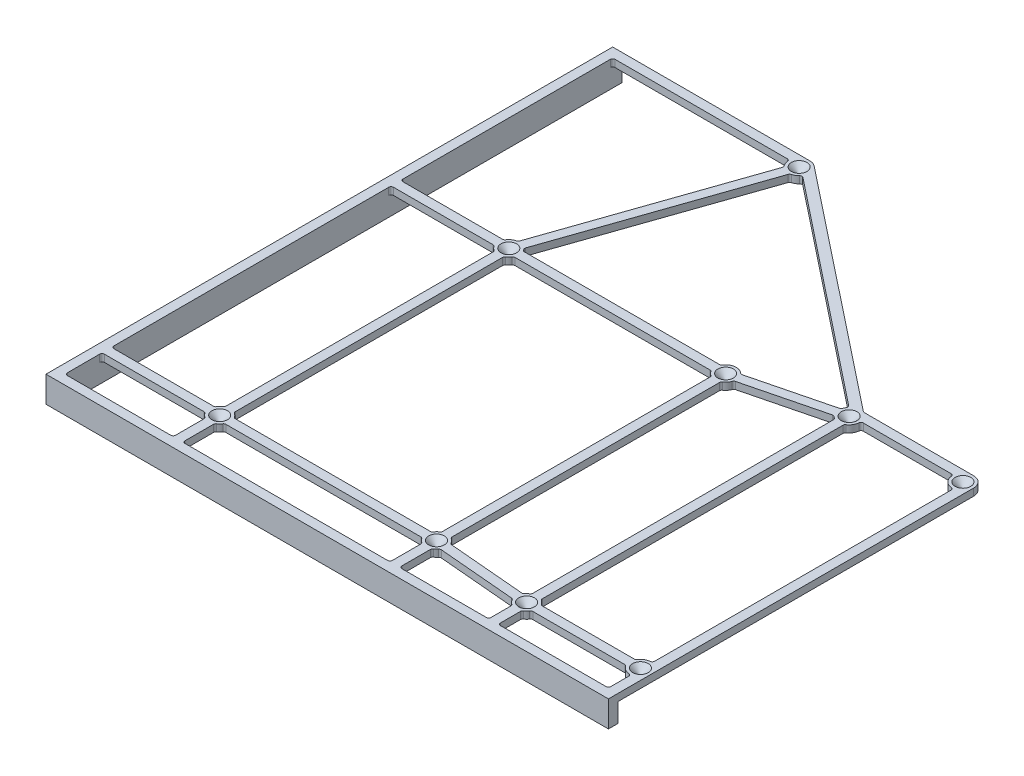
from build123d import *

# Parameters (mm, degrees)
SKETCH1_R           = 0.5
BOSS_EXTRUDE1_DEPTH = 3
BOSS_EXTRUDE2_DEPTH = 8
CHAMFER1_SIZE       = 2.8
FILLET1_R           = 1


with BuildPart() as part:
    # Sketch1 → Boss-Extrude1 (new body)
    with BuildSketch(Plane(origin=(0, 0, 0), x_dir=(1, 0, 0), z_dir=(0, 1, 0))):
        with BuildLine():
            Line((0, 234.968858619), (-4, 234.968858619))
            Line((-4, 234.968858619), (-4, -4))
            Line((-4, -4), (233.18, -4))
            Line((233.18, -4), (233.18, 0))
            Line((233.18, 0), (233.18, 150))
            ThreePointArc((233.18, 150), (231.861980515, 153.181980515), (228.68, 154.5))
            Line((228.68, 154.5), (182.246826387, 154.5))
            Line((182.246826387, 154.5), (81.928603431, 233.995744418))
            ThreePointArc((81.928603431, 233.995744418), (80.613471367, 234.718622501), (79.133773103, 234.968858619))
            Line((79.133773103, 234.968858619), (0, 234.968858619))
        make_face()
        with Locations((47.62, 139.54)):
            Circle(SKETCH1_R, mode=Mode.SUBTRACT)
        with Locations((139.06, 139.54)):
            Circle(SKETCH1_R, mode=Mode.SUBTRACT)
        with Locations((139.06, 17.62)):
            Circle(SKETCH1_R, mode=Mode.SUBTRACT)
        with Locations((47.62, 17.62)):
            Circle(SKETCH1_R, mode=Mode.SUBTRACT)
        with Locations((180.68, 150)):
            Circle(SKETCH1_R, mode=Mode.SUBTRACT)
        with Locations((228.68, 150)):
            Circle(SKETCH1_R, mode=Mode.SUBTRACT)
        with Locations((228.68, 14)):
            Circle(SKETCH1_R, mode=Mode.SUBTRACT)
        with Locations((180.68, 14)):
            Circle(SKETCH1_R, mode=Mode.SUBTRACT)
        with Locations((79.133773103, 230.468858619)):
            Circle(SKETCH1_R, mode=Mode.SUBTRACT)
        with BuildLine():
            Line((0, 0), (0, 15.62))
            Line((0, 15.62), (43.588871126, 15.62))
            ThreePointArc((43.588871126, 15.62), (44.438019485, 14.438019485), (45.62, 13.588871126))
            Line((45.62, 13.588871126), (45.62, 0))
            Line((45.62, 0), (0, 0))
        make_face(mode=Mode.SUBTRACT)
        with BuildLine():
            Line((229.18, 0), (182.68, 0))
            Line((182.68, 0), (182.68, 9.968871126))
            ThreePointArc((182.68, 9.968871126), (183.861980515, 10.818019485), (184.711128874, 12))
            Line((184.711128874, 12), (224.648871126, 12))
            ThreePointArc((224.648871126, 12), (226.524754811, 10.049693914), (229.18, 9.527864045))
            Line((229.18, 9.527864045), (229.18, 0))
        make_face(mode=Mode.SUBTRACT)
        with BuildLine():
            Line((229.18, 18.472135955), (229.18, 145.527864045))
            ThreePointArc((229.18, 145.527864045), (225.498019485, 146.818019485), (224.207864045, 150.5))
            Line((224.207864045, 150.5), (185.152135955, 150.5))
            ThreePointArc((185.152135955, 150.5), (184.630306086, 147.844754811), (182.68, 145.968871126))
            Line((182.68, 145.968871126), (182.68, 18.031128874))
            ThreePointArc((182.68, 18.031128874), (183.861980515, 17.181980515), (184.711128874, 16))
            Line((184.711128874, 16), (224.648871126, 16))
            ThreePointArc((224.648871126, 16), (226.524754811, 17.950306086), (229.18, 18.472135955))
        make_face(mode=Mode.SUBTRACT)
        with BuildLine():
            Line((178.68, 145.968871126), (178.68, 18.031128874))
            ThreePointArc((178.68, 18.031128874), (177.639002471, 17.31697664), (176.837333591, 16.341776007))
            Line((176.837333591, 16.341776007), (143.249267507, 19.26317916))
            ThreePointArc((143.249267507, 19.26317916), (142.37697664, 20.660997529), (141.06, 21.651128874))
            Line((141.06, 21.651128874), (141.06, 135.508871126))
            ThreePointArc((141.06, 135.508871126), (142.608645436, 136.772850642), (143.457034144, 138.58287371))
            Line((143.457034144, 138.58287371), (177.257932545, 147.077765524))
            ThreePointArc((177.257932545, 147.077765524), (177.912850642, 146.451354564), (178.68, 145.968871126))
        make_face(mode=Mode.SUBTRACT)
        with BuildLine():
            Line((177.485489417, 153.169400911), (82.949357092, 228.083210108))
            ThreePointArc((82.949357092, 228.083210108), (81.560143982, 226.679040107), (79.703437326, 226.00506173))
            Line((79.703437326, 226.00506173), (50.829786439, 142.693929457))
            ThreePointArc((50.829786439, 142.693929457), (51.286142651, 142.149482336), (51.651128874, 141.54))
            Line((51.651128874, 141.54), (135.028871126, 141.54))
            ThreePointArc((135.028871126, 141.54), (138.507398823, 144.005941327), (142.482067455, 142.462234476))
            Line((142.482067455, 142.462234476), (176.282965856, 150.95712629))
            ThreePointArc((176.282965856, 150.95712629), (176.726339976, 152.149086414), (177.485489417, 153.169400911))
        make_face(mode=Mode.SUBTRACT)
        with BuildLine():
            Line((178.68, 9.968871126), (178.68, 0))
            Line((178.68, 0), (141.06, 0))
            Line((141.06, 0), (141.06, 13.588871126))
            ThreePointArc((141.06, 13.588871126), (142.100997529, 14.30302336), (142.902666409, 15.278223993))
            Line((142.902666409, 15.278223993), (176.490732493, 12.35682084))
            ThreePointArc((176.490732493, 12.35682084), (177.36302336, 10.959002471), (178.68, 9.968871126))
        make_face(mode=Mode.SUBTRACT)
        with BuildLine():
            Line((74.661637148, 230.968858619), (0, 230.968858619))
            Line((0, 230.968858619), (0, 141.54))
            Line((0, 141.54), (43.588871126, 141.54))
            ThreePointArc((43.588871126, 141.54), (45.010517664, 143.206142651), (47.050335776, 144.00379689))
            Line((47.050335776, 144.00379689), (75.923986664, 227.314929163))
            ThreePointArc((75.923986664, 227.314929163), (74.880446988, 228.999431192), (74.661637148, 230.968858619))
        make_face(mode=Mode.SUBTRACT)
        with BuildLine():
            Line((51.651128874, 15.62), (135.028871126, 15.62))
            ThreePointArc((135.028871126, 15.62), (135.878019485, 14.438019485), (137.06, 13.588871126))
            Line((137.06, 13.588871126), (137.06, 0))
            Line((137.06, 0), (49.62, 0))
            Line((49.62, 0), (49.62, 13.588871126))
            ThreePointArc((49.62, 13.588871126), (50.801980515, 14.438019485), (51.651128874, 15.62))
        make_face(mode=Mode.SUBTRACT)
        with BuildLine():
            Line((51.651128874, 19.62), (135.028871126, 19.62))
            ThreePointArc((135.028871126, 19.62), (135.878019485, 20.801980515), (137.06, 21.651128874))
            Line((137.06, 21.651128874), (137.06, 135.508871126))
            ThreePointArc((137.06, 135.508871126), (135.878019485, 136.358019485), (135.028871126, 137.54))
            Line((135.028871126, 137.54), (51.651128874, 137.54))
            ThreePointArc((51.651128874, 137.54), (50.801980515, 136.358019485), (49.62, 135.508871126))
            Line((49.62, 135.508871126), (49.62, 21.651128874))
            ThreePointArc((49.62, 21.651128874), (50.801980515, 20.801980515), (51.651128874, 19.62))
        make_face(mode=Mode.SUBTRACT)
        with BuildLine():
            Line((43.588871126, 137.54), (0, 137.54))
            Line((0, 137.54), (0, 19.62))
            Line((0, 19.62), (43.588871126, 19.62))
            ThreePointArc((43.588871126, 19.62), (44.438019485, 20.801980515), (45.62, 21.651128874))
            Line((45.62, 21.651128874), (45.62, 135.508871126))
            ThreePointArc((45.62, 135.508871126), (44.438019485, 136.358019485), (43.588871126, 137.54))
        make_face(mode=Mode.SUBTRACT)
    extrude(amount=BOSS_EXTRUDE1_DEPTH)

    # Sketch2 → Boss-Extrude2 (add)
    with BuildSketch(Plane.XZ):
        Polygon((-4, 4), (-4, -234.968858619), (0, -234.968858619), (0, 0), (233.18, 0), (233.18, 4), align=None)
    extrude(amount=BOSS_EXTRUDE2_DEPTH)

    # Chamfer1
    chamfer1_edges = [part.edges().sort_by_distance(p)[0] for p in [
        (78.633773103, 3, -230.468858619),
        (47.12, 3, -139.54),
        (138.56, 3, -139.54),
        (138.56, 3, -17.62),
        (47.12, 3, -17.62),
        (180.18, 3, -150),
        (228.18, 3, -150),
        (228.18, 3, -14),
        (180.18, 3, -14),
    ]]
    chamfer(chamfer1_edges, length=CHAMFER1_SIZE)

    # Fillet1
    fillet1_edges = [part.edges().sort_by_distance(p)[0] for p in [
        (229.18, 1.5, -9.527864045),
        (224.648871126, 1.5, -12),
        (184.711128874, 1.5, -12),
        (182.68, 1.5, -9.968871126),
        (182.68, 1.5, 0),
        (229.18, 1.5, 0),
        (135.028871126, 1.5, -141.54),
        (142.482067455, 1.5, -142.462234476),
        (176.282965856, 1.5, -150.95712629),
        (177.485489417, 1.5, -153.169400911),
        (82.949357092, 1.5, -228.083210108),
        (79.703437326, 1.5, -226.00506173),
        (50.829786439, 1.5, -142.693929457),
        (51.651128874, 1.5, -141.54),
        (178.68, 1.5, -9.968871126),
        (176.490732493, 1.5, -12.35682084),
        (142.902666409, 1.5, -15.278223993),
        (141.06, 1.5, -13.588871126),
        (141.06, 1.5, 0),
        (178.68, 1.5, 0),
        (176.837333591, 1.5, -16.341776007),
        (178.68, 1.5, -18.031128874),
        (178.68, 1.5, -145.968871126),
        (177.257932545, 1.5, -147.077765524),
        (143.457034144, 1.5, -138.58287371),
        (141.06, 1.5, -135.508871126),
        (141.06, 1.5, -21.651128874),
        (143.249267507, 1.5, -19.26317916),
        (182.246826387, 1.5, -154.5),
        (75.923986664, 1.5, -227.314929163),
        (74.661637148, 1.5, -230.968858619),
        (0, 1.5, -230.968858619),
        (0, 1.5, -141.54),
        (43.588871126, 1.5, -141.54),
        (47.050335776, 1.5, -144.00379689),
        (137.06, 1.5, -13.588871126),
        (135.028871126, 1.5, -15.62),
        (51.651128874, 1.5, -15.62),
        (49.62, 1.5, -13.588871126),
        (49.62, 1.5, 0),
        (137.06, 1.5, 0),
        (135.028871126, 1.5, -19.62),
        (137.06, 1.5, -21.651128874),
        (137.06, 1.5, -135.508871126),
        (135.028871126, 1.5, -137.54),
        (51.651128874, 1.5, -137.54),
        (49.62, 1.5, -135.508871126),
        (49.62, 1.5, -21.651128874),
        (51.651128874, 1.5, -19.62),
        (43.588871126, 1.5, -19.62),
        (45.62, 1.5, -21.651128874),
        (45.62, 1.5, -135.508871126),
        (43.588871126, 1.5, -137.54),
        (0, 1.5, -137.54),
        (0, 1.5, -19.62),
        (0, -2.5, 0),
        (45.62, 1.5, 0),
        (45.62, 1.5, -13.588871126),
        (43.588871126, 1.5, -15.62),
        (0, 1.5, -15.62),
        (224.648871126, 1.5, -16),
        (229.18, 1.5, -18.472135955),
        (229.18, 1.5, -145.527864045),
        (224.207864045, 1.5, -150.5),
        (185.152135955, 1.5, -150.5),
        (182.68, 1.5, -145.968871126),
        (182.68, 1.5, -18.031128874),
        (184.711128874, 1.5, -16),
    ]]
    fillet(fillet1_edges, radius=FILLET1_R)


solid = part.part
